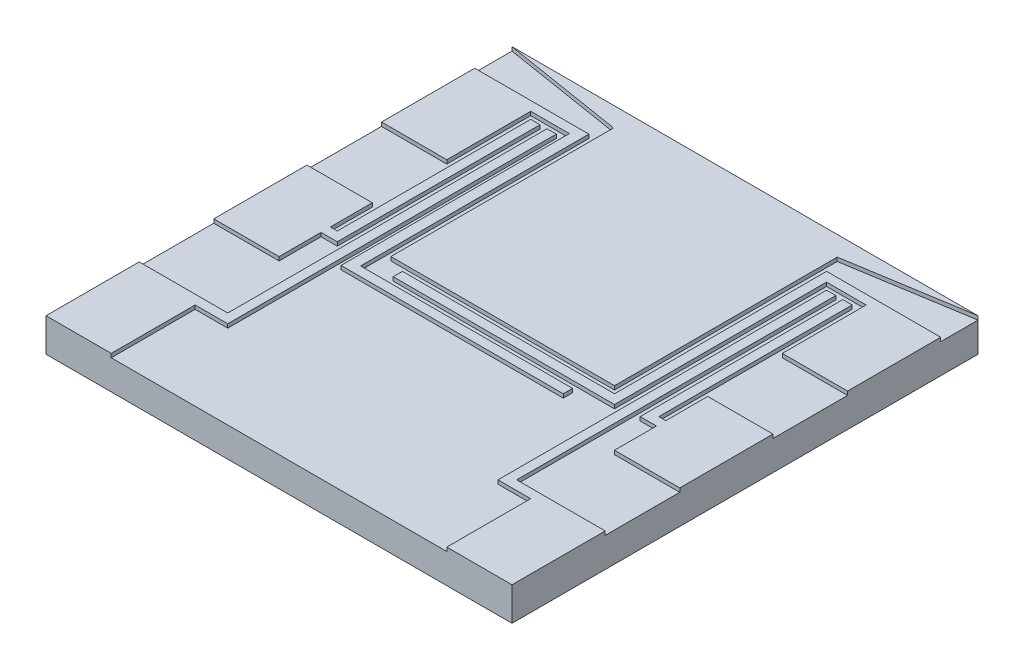
from build123d import *

# Parameters (mm, degrees)
SKETCH1_W           = 10
SKETCH1_H           = 10
BOSS_EXTRUDE2_DEPTH = 0.204346
SKETCH3_W           = 25
SKETCH3_H           = 25
BOSS_EXTRUDE3_DEPTH = 1.5875


with BuildPart() as part:
    # Sketch1 → Boss-Extrude2 (new body)
    with BuildSketch(Plane(origin=(0, 0, 0), x_dir=(1, 0, 0), z_dir=(0, 1, 0))):
        Polygon((3.5, 5), (0, 5), (0, 0), (3.5, 0), (3.5, 4.5), (5.25, 4.5), (5.25, 22.125), (4.75, 22.125), (4.75, 5), align=None)
        Polygon((3.503473693, 14), (0, 14), (0, 9), (3.503473693, 9), (3.503473693, 11.25), (4.378473693, 11.25), (4.378473693, 22.125), (3.878473693, 22.125), (3.878473693, 11.75), (3.503473693, 11.75), align=None)
        Polygon((3.503473693, 23), (0, 23), (0, 18), (3.503473693, 18), (3.503473693, 22.5), (5.576932067, 22.5), (5.576932067, 10.25), (17.5, 10.25), (17.5, 10.75), (6.125, 10.75), (6.125, 23), align=None)
        Polygon((18.5, 23.946155101), (18.5, 12), (6.5, 12), (6.5, 23.946155101), (0, 25), (25, 25), align=None)
        with Locations((12.5, 18)):
            Rectangle(SKETCH1_W, SKETCH1_H, mode=Mode.SUBTRACT)
        with Locations((12.5, 18)):
            Rectangle(SKETCH1_W, SKETCH1_H)
        Polygon((25, 18), (25, 23), (21.5, 23), (18.875, 23), (18.875, 11.625), (7.5, 11.625), (7.5, 11.125), (19.375, 11.125), (19.375, 22.5), (21.5, 22.5), (21.5, 18), align=None)
        Polygon((25, 9), (25, 14), (21.5, 14), (21.5, 11.75), (21.125, 11.75), (21.125, 22.125), (20.625, 22.125), (20.625, 11.25), (21.5, 11.25), (21.5, 9), align=None)
        Polygon((25, 0), (25, 5), (21.5, 5), (20.25, 5), (20.25, 22.125), (19.75, 22.125), (19.75, 4.5), (21.5, 4.5), (21.5, 0), align=None)
    extrude(amount=BOSS_EXTRUDE2_DEPTH)

    # Sketch3 → Boss-Extrude3 (add)
    with BuildSketch(Plane(origin=(0, 0, 0), x_dir=(1, 0, 0), z_dir=(0, 1, 0))):
        with Locations((12.5, 12.5)):
            Rectangle(SKETCH3_W, SKETCH3_H)
    extrude(amount=-BOSS_EXTRUDE3_DEPTH)


solid = part.part
